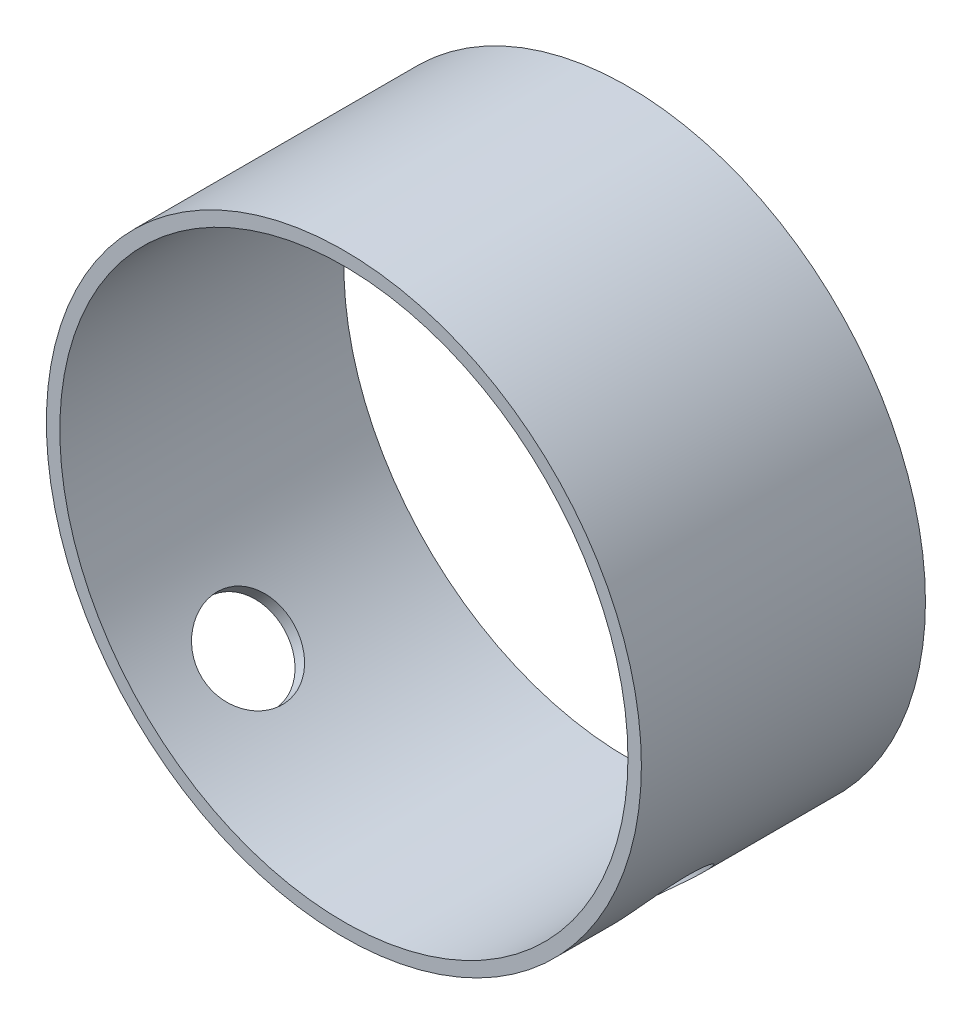
from build123d import *

# Parameters (mm, degrees)
SKETCH1_R           = 39.9034
SKETCH1_R_2         = 38.1
BOSS_EXTRUDE1_DEPTH = 19.05
SKETCH2_R           = 6.1849
CUT_EXTRUDE1_DEPTH  = 60.560600762
SKETCH3_R           = 6.1849
CUT_EXTRUDE2_DEPTH  = 60.560600928


with BuildPart() as part:
    # Sketch1 → Boss-Extrude1 (new, symmetric)
    with BuildSketch(Plane.XY):
        Circle(SKETCH1_R)
        Circle(SKETCH1_R_2, mode=Mode.SUBTRACT)
    extrude(amount=BOSS_EXTRUDE1_DEPTH, both=True)

    # Sketch2 → Cut-Extrude1 (cut, through all)
    with BuildSketch(Plane(origin=(0, 0, 0), x_dir=(0, 0, 1), z_dir=(-0.7071067811865488, 0.7071067811865464, 0))):
        with Locations((5.08, 0)):
            Circle(SKETCH2_R)
    extrude(amount=-CUT_EXTRUDE1_DEPTH, mode=Mode.SUBTRACT)

    # Sketch3 → Cut-Extrude2 (cut, through all)
    with BuildSketch(Plane(origin=(0, 0, 0), x_dir=(0, 0, 1), z_dir=(-0.7071067811865464, -0.7071067811865488, 0))):
        with Locations((5.08, 0)):
            Circle(SKETCH3_R)
    extrude(amount=CUT_EXTRUDE2_DEPTH, mode=Mode.SUBTRACT)


solid = part.part
